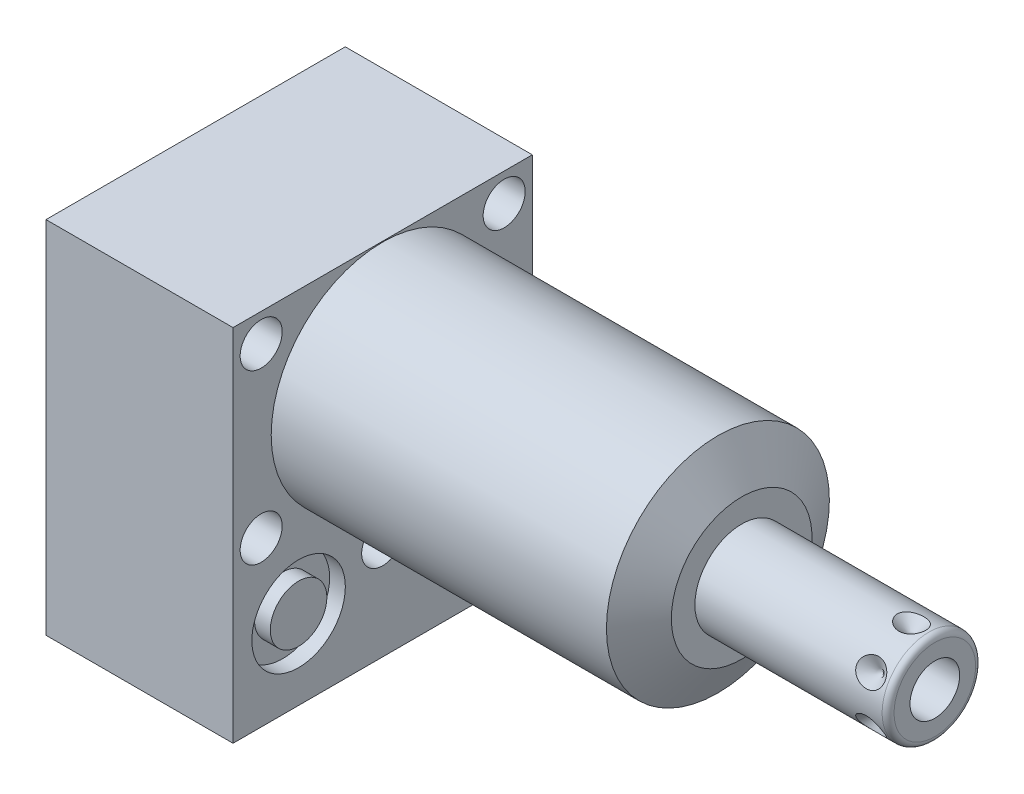
from build123d import *

# Parameters (mm, degrees)
SKETCH1_W           = 50.8
SKETCH1_H           = 61.1124
EXTRUDE1_DEPTH      = 60.9346
EXTRUDE1_DEPTH_BACK = 31.75
CUT_EXTRUDE1_REACH  = 62.935
SKETCH2_W           = 50.8
SKETCH2_H           = 61.1124
SKETCH2_R           = 18.923
SKETCH18_R          = 7.9375
CUT_EXTRUDE2_DEPTH  = 2.667
SKETCH19_R          = 7.9375
CUT_EXTRUDE3_DEPTH  = 2.667
SKETCH20_R          = 9.525
CUT_EXTRUDE4_DEPTH  = 0.254
SKETCH12_R          = 6.4389
EXTRUDE2_DEPTH      = 1.651
EXTRUDE3_START      = -2.667
SKETCH13_R          = 4.8006
EXTRUDE3_DEPTH      = 2.667
SKETCH14_R          = 1.7653
SKETCH15_R          = 1.7653
CIRPATTERN1_COUNT   = 6
SKETCH21_W          = 3.5687
SKETCH21_H          = 31.75
HOLE1_AT_2_COUNT    = 2
HOLE1_AT_2_PITCH    = 44.445239059
HOLE1_AT_3_COUNT    = 2
HOLE1_AT_3_PITCH    = 28.5496
HOLE1_AT_4_COUNT    = 2
HOLE1_AT_4_PITCH    = 41.2496
HOLE1_AT_5_COUNT    = 2
HOLE1_AT_5_PITCH    = 50.165816652
SKETCH24_R          = 4.8006
EXTRUDE4_DEPTH      = 2.667


with BuildPart() as part:
    # Sketch1 → Extrude1 (new body, two sides)
    with BuildSketch(Plane(origin=(0, 0, 0), x_dir=(0, 0, -1), z_dir=(1, 0, 0))) as extrude1_sk:
        with Locations((0, -11.5062)):
            Rectangle(SKETCH1_W, SKETCH1_H)
    extrude(amount=EXTRUDE1_DEPTH)
    extrude(extrude1_sk.sketch, amount=-EXTRUDE1_DEPTH_BACK)

    # Sketch2 → Cut-Extrude1 (cut, up to next)
    with BuildSketch(Plane(origin=(0, 0, 0), x_dir=(0, 0, -1), z_dir=(1, 0, 0)), mode=Mode.PRIVATE) as cut_extrude1_sk1:
        with Locations((0, -11.5062)):
            Rectangle(SKETCH2_W, SKETCH2_H)
        Circle(SKETCH2_R, mode=Mode.SUBTRACT)
    cut_extrude1_tool1 = extrude(cut_extrude1_sk1.sketch, amount=CUT_EXTRUDE1_REACH, mode=Mode.PRIVATE) & part.part
    add(cut_extrude1_tool1.solids().sort_by_distance((0, 18.970531, 0))[0], mode=Mode.SUBTRACT)

    # Sketch3 → Cut-Revolve1 (revolve, cut)
    with BuildSketch(Plane.XY, mode=Mode.PRIVATE) as cut_revolve1_sk:
        Polygon((56.90180837, 18.923), (60.9346, 11.938), (60.9346, 18.923), align=None)
    revolve(cut_revolve1_sk.sketch.rotate(Axis((56.700168788, 0, 0), (1, 0, 0)), 90), axis=Axis((56.700168788, 0, 0), (1, 0, 0)), mode=Mode.SUBTRACT)  # turned: the seam where the file's is

    # S2D0002 → Cut-Revolve2 (revolve, cut)
    with BuildSketch(Plane(origin=(-29.083, -28.575, 14.2748), x_dir=(0, 1, 0), z_dir=(0, 0, 1)), mode=Mode.PRIVATE) as cut_revolve2_sk:
        Polygon((0, 0), (4.5466, 0), (4.106586662, -2.0701), (3.4544, -2.722286662), (3.4544, -13.97), (0, -13.97), align=None)
    revolve(cut_revolve2_sk.sketch.rotate(Axis((-14.4145, -28.575, 14.2748), (-1, 0, 0)), 90), axis=Axis((-14.4145, -28.575, 14.2748), (-1, 0, 0)), mode=Mode.SUBTRACT)  # turned: the seam where the file's is

    # Sketch5 → Cut-Revolve3 (revolve, cut)
    with BuildSketch(Plane(origin=(-29.083, -28.575, -14.2748), x_dir=(0, 1, 0), z_dir=(0, 0, 1)), mode=Mode.PRIVATE) as cut_revolve3_sk:
        Polygon((0, 0), (4.5466, 0), (4.106586662, -2.0701), (3.4544, -2.722286662), (3.4544, -13.97), (0, -13.97), align=None)
    revolve(cut_revolve3_sk.sketch.rotate(Axis((-14.4145, -28.575, -14.2748), (-1, 0, 0)), 90), axis=Axis((-14.4145, -28.575, -14.2748), (-1, 0, 0)), mode=Mode.SUBTRACT)  # turned: the seam where the file's is

    # Sketch6 → Cut-Revolve4 (revolve, cut)
    with BuildSketch(Plane(origin=(-2.667, -28.575, 14.2748), x_dir=(0, -1, 0), z_dir=(0, 0, 1)), mode=Mode.PRIVATE) as cut_revolve4_sk:
        Polygon((0, 0), (4.5466, 0), (4.106586662, -2.0701), (3.4544, -2.722286662), (3.4544, -12.192), (0, -12.192), align=None)
    revolve(cut_revolve4_sk.sketch.rotate(Axis((-15.4686, -28.575, 14.2748), (1, 0, 0)), 90), axis=Axis((-15.4686, -28.575, 14.2748), (1, 0, 0)), mode=Mode.SUBTRACT)  # turned: the seam where the file's is

    # Sketch7 → Cut-Revolve5 (revolve, cut)
    with BuildSketch(Plane(origin=(-2.667, -28.575, -14.2748), x_dir=(0, -1, 0), z_dir=(0, 0, 1)), mode=Mode.PRIVATE) as cut_revolve5_sk:
        Polygon((0, 0), (4.5466, 0), (4.106586662, -2.0701), (3.4544, -2.722286662), (3.4544, -12.192), (0, -12.192), align=None)
    revolve(cut_revolve5_sk.sketch.rotate(Axis((-15.4686, -28.575, -14.2748), (1, 0, 0)), 90), axis=Axis((-15.4686, -28.575, -14.2748), (1, 0, 0)), mode=Mode.SUBTRACT)  # turned: the seam where the file's is

    # Sketch18 → Cut-Extrude2 (cut)
    with BuildSketch(Plane.ZY.offset(31.75)):
        with Locations((-14.2748, -28.575)):
            Circle(SKETCH18_R)
        with Locations((14.2748, -28.575)):
            Circle(SKETCH18_R)
    extrude(amount=-CUT_EXTRUDE2_DEPTH, mode=Mode.SUBTRACT)

    # Sketch19 → Cut-Extrude3 (cut)
    with BuildSketch(Plane(origin=(0, 0, 0), x_dir=(0, 0, -1), z_dir=(1, 0, 0))):
        with Locations((-14.2748, -28.575)):
            Circle(SKETCH19_R)
        with Locations((14.2748, -28.575)):
            Circle(SKETCH19_R)
    extrude(amount=-CUT_EXTRUDE3_DEPTH, mode=Mode.SUBTRACT)

    # Sketch8 → Cut-Revolve6 (revolve, cut)
    with BuildSketch(Plane(origin=(-15.875, -43.688, 14.2748), x_dir=(-1, 0, 0), z_dir=(0, 0, 1)), mode=Mode.PRIVATE) as cut_revolve6_sk:
        Polygon((0, -1.8796), (6.1849, -1.8796), (5.642306865, -4.4323), (4.9784, -5.096206865), (4.9784, -20.9296), (0, -20.9296), align=None)
    revolve(cut_revolve6_sk.sketch.rotate(Axis((-15.875, -17.018, 14.2748), (0, -1, 0)), 270), axis=Axis((-15.875, -17.018, 14.2748), (0, -1, 0)), mode=Mode.SUBTRACT)  # turned: the seam where the file's is

    # Sketch9 → Cut-Revolve7 (revolve, cut)
    with BuildSketch(Plane(origin=(-15.875, -43.688, -14.2748), x_dir=(-1, 0, 0), z_dir=(0, 0, 1)), mode=Mode.PRIVATE) as cut_revolve7_sk:
        Polygon((0, -1.8796), (6.1849, -1.8796), (5.642306865, -4.4323), (4.9784, -5.096206865), (4.9784, -20.9296), (0, -20.9296), align=None)
    revolve(cut_revolve7_sk.sketch.rotate(Axis((-15.875, -17.018, -14.2748), (0, -1, 0)), 270), axis=Axis((-15.875, -17.018, -14.2748), (0, -1, 0)), mode=Mode.SUBTRACT)  # turned: the seam where the file's is

    # Sketch20 → Cut-Extrude4 (cut)
    with BuildSketch(Plane.XZ.offset(42.0624)):
        with Locations(Location((-15.875, 14.2748, 0), (0, 0, 270))):  # turned: the seam where the file's is
            Circle(SKETCH20_R)
        with Locations(Location((-15.875, -14.2748, 0), (0, 0, 270))):  # turned: the seam where the file's is
            Circle(SKETCH20_R)
    extrude(amount=-CUT_EXTRUDE4_DEPTH, mode=Mode.SUBTRACT)

    # Sketch10 → Revolve1 (revolve)
    with BuildSketch(Plane.XY, mode=Mode.PRIVATE) as revolve1_sk:
        with BuildLine():
            Line((60.9346, 0), (60.9346, 7.9375))
            Line((60.9346, 7.9375), (92.71, 7.9375))
            ThreePointArc((92.71, 7.9375), (93.42842049, 7.63992049), (93.726, 6.9215))
            Line((93.726, 6.9215), (93.726, 0))
            Line((93.726, 0), (60.9346, 0))
        make_face()
    revolve(revolve1_sk.sketch.rotate(Axis((59.59348, 0, 0), (1, 0, 0)), 90), axis=Axis((59.59348, 0, 0), (1, 0, 0)))  # turned: the seam where the file's is

    # S2D0001 → Cut-Revolve8 (revolve, cut)
    with BuildSketch(Plane(origin=(87.757, -4.2164, 0), x_dir=(0, -1, 0), z_dir=(0, 0, 1)), mode=Mode.PRIVATE) as cut_revolve8_sk:
        Polygon((0, 5.969), (0, -9.271), (-4.2164, -11.804468714), (-4.2164, 5.969), align=None)
    revolve(cut_revolve8_sk.sketch.rotate(Axis((62.891960697, 0, 0), (1, 0, 0)), 270), axis=Axis((62.891960697, 0, 0), (1, 0, 0)), mode=Mode.SUBTRACT)  # turned: the seam where the file's is

    # Sketch12 → Extrude2 (add)
    with BuildSketch(Plane(origin=(-31.75, -41.8084, 0), x_dir=(0, 0, -1), z_dir=(0, -1, 0))):
        with Locations((-14.2748, 15.875)):
            Circle(SKETCH12_R)
    extrude(amount=EXTRUDE2_DEPTH)

    # Sketch13 → Extrude3 (add)
    with BuildSketch(Plane(origin=(0, 0, 0), x_dir=(0, 0, -1), z_dir=(1, 0, 0)).offset(EXTRUDE3_START)):
        with Locations((-14.2748, -28.575)):
            Circle(SKETCH13_R)
    extrude(amount=EXTRUDE3_DEPTH)

    # Sketch16 → Cut-Revolve9 (revolve, cut)
    with BuildSketch(Plane(origin=(83.7946, -7.9375, 0), x_dir=(-1, 0, 0), z_dir=(0, 0, 1)), mode=Mode.PRIVATE) as cut_revolve9_sk:
        Polygon((-5.969, 0), (-3.556, 0), (-5.969, -2.413), align=None)
    cut_revolve9 = revolve(cut_revolve9_sk.sketch.rotate(Axis((89.7636, -4.132061843, 0), (0, -1, 0)), 90), axis=Axis((89.7636, -4.132061843, 0), (0, -1, 0)), mode=Mode.SUBTRACT)  # turned: the seam where the file's is

    # CirPattern1: Cut-Revolve9 ×6 about axis
    cirpattern1_axis = Axis((60.9356, 0, 0), (-1, 0, 0))
    for i in range(1, CIRPATTERN1_COUNT):
        add(cut_revolve9.rotate(cirpattern1_axis, i * 360 / CIRPATTERN1_COUNT), mode=Mode.SUBTRACT)

    # Sketch21 → Hole1 (revolve, cut)
    with BuildSketch(Plane(origin=(0, 14.2748, 20.6248), x_dir=(0, 0, -1), z_dir=(0, 1, 0))):
        with Locations((1.78435, 15.875)):
            Rectangle(SKETCH21_W, SKETCH21_H)
    hole1 = revolve(axis=Axis((-110, 14.2748, 20.6248), (1, 0, 0)), mode=Mode.SUBTRACT)

    # Hole1 at 2: Hole1 ×2
    with Locations(*[Vector(0, -0.885809163, -0.464049703) * (i * HOLE1_AT_2_PITCH) for i in range(1, HOLE1_AT_2_COUNT)]):
        add(hole1, mode=Mode.SUBTRACT)

    # Hole1 at 3: Hole1 ×2
    with Locations(*[(0, -i * HOLE1_AT_3_PITCH, 0) for i in range(1, HOLE1_AT_3_COUNT)]):
        add(hole1, mode=Mode.SUBTRACT)

    # Hole1 at 4: Hole1 ×2
    with Locations(*[(0, 0, -i * HOLE1_AT_4_PITCH) for i in range(1, HOLE1_AT_4_COUNT)]):
        add(hole1, mode=Mode.SUBTRACT)

    # Hole1 at 5: Hole1 ×2
    with Locations(*[Vector(0, -0.569104659, -0.822265095) * (i * HOLE1_AT_5_PITCH) for i in range(1, HOLE1_AT_5_COUNT)]):
        add(hole1, mode=Mode.SUBTRACT)

    # Sketch24 → Extrude4 (add)
    with BuildSketch(Plane.ZY.offset(29.083)):
        with Locations(Location((14.2748, -28.575, 0), (0, 0, 180))):  # turned: the seam where the file's is
            Circle(SKETCH24_R)
    extrude(amount=EXTRUDE4_DEPTH)


with BuildPart() as body_2:
    # Sketch14 → Revolve2 (revolve)
    with BuildSketch(Plane(origin=(0, -28.575, -14.2748), x_dir=(0, 0, -1), z_dir=(0, -1, 0)), mode=Mode.PRIVATE) as revolve2_sk:
        with Locations((6.1722, -0.9017)):
            Circle(SKETCH14_R)
    revolve(revolve2_sk.sketch.rotate(Axis((-2.84353, -28.575, -14.2748), (1, 0, 0)), 180), axis=Axis((-2.84353, -28.575, -14.2748), (1, 0, 0)))  # turned: the seam where the file's is


with BuildPart() as body_3:
    # Sketch15 → Revolve3 (revolve)
    with BuildSketch(Plane(origin=(0, -28.575, -14.2748), x_dir=(0, 0, -1), z_dir=(0, -1, 0)), mode=Mode.PRIVATE) as revolve3_sk:
        with Locations((6.1722, -30.8483)):
            Circle(SKETCH15_R)
    revolve(revolve3_sk.sketch.rotate(Axis((-32.79013, -28.575, -14.2748), (1, 0, 0)), 180), axis=Axis((-32.79013, -28.575, -14.2748), (1, 0, 0)))  # turned: the seam where the file's is


solid = Compound([part.part, body_2.part, body_3.part])
